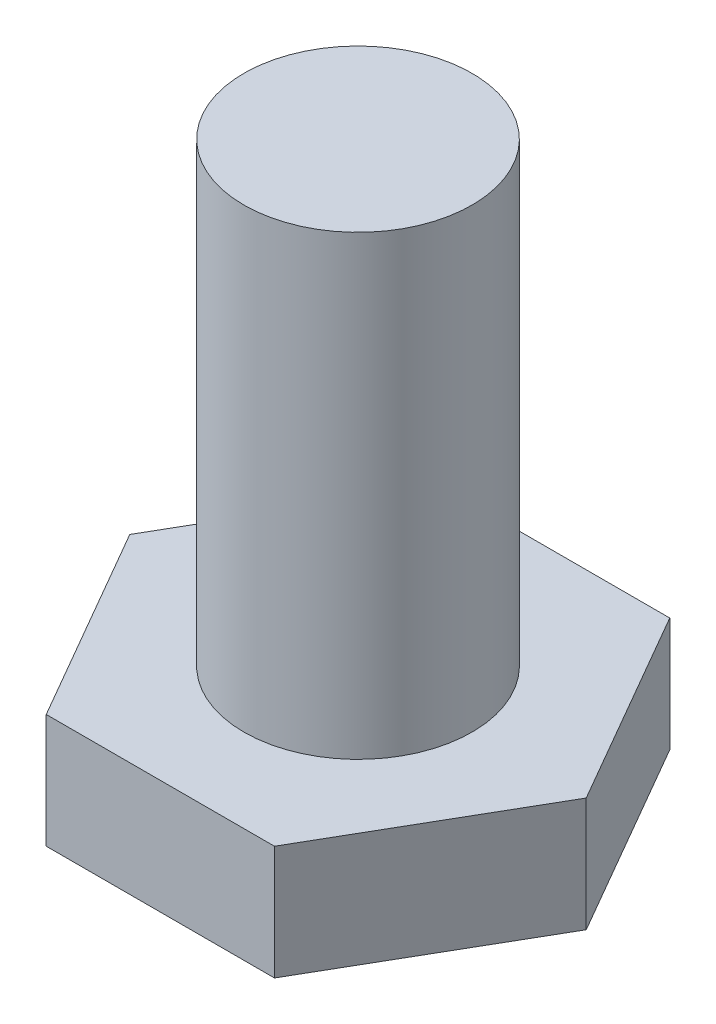
from build123d import *

# Parameters (mm, degrees)
BOSS_EXTRUDE1_DEPTH = 3
SKETCH2_R           = 3
BOSS_EXTRUDE2_DEPTH = 12


with BuildPart() as part:
    # Sketch1 → Boss-Extrude1 (new body)
    with BuildSketch(Plane(origin=(0, 0, 0), x_dir=(1, 0, 0), z_dir=(0, 1, 0))):
        Polygon((3, -5.196152423), (6, 0), (3, 5.196152423), (-3, 5.196152423), (-6, 0), (-3, -5.196152423), align=None)
    extrude(amount=BOSS_EXTRUDE1_DEPTH)

    # Sketch2 → Boss-Extrude2 (add)
    with BuildSketch(Plane(origin=(0, 3, 0), x_dir=(1, 0, 0), z_dir=(0, 1, 0))):
        Circle(SKETCH2_R)
    extrude(amount=BOSS_EXTRUDE2_DEPTH)


solid = part.part
